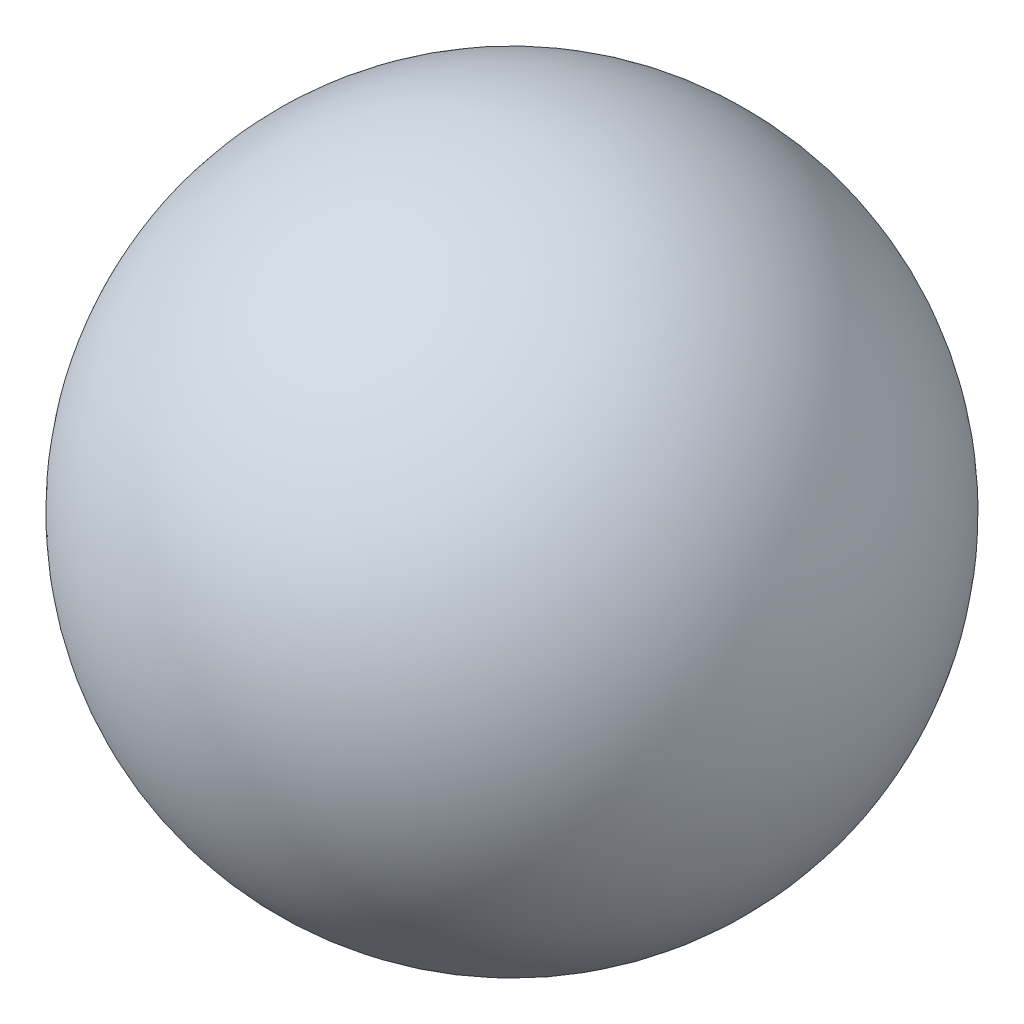
from build123d import *


with BuildPart() as part:
    # Esquisse1 → Base-Révolution (revolve)
    with BuildSketch(Plane.XY):
        with BuildLine():
            Line((0.75, 3.25), (3.25, 3.25))
            ThreePointArc((3.25, 3.25), (2, 4.5), (0.75, 3.25))
        make_face()
    revolve(axis=Axis((2, 3.25, 0), (1, 0, 0)))


solid = part.part
